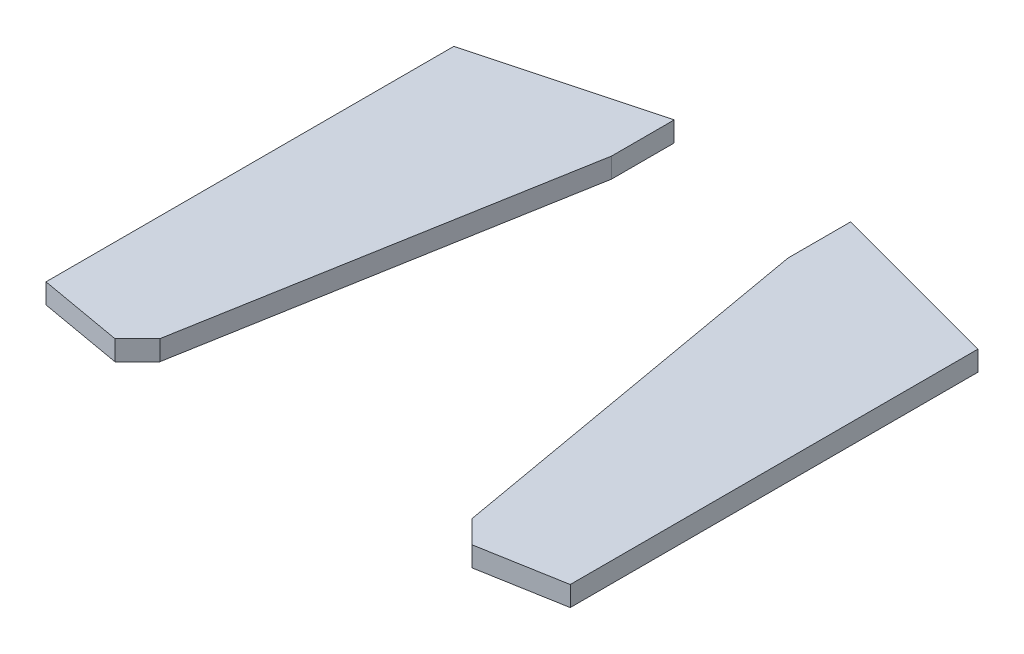
from build123d import *

# Parameters (mm, degrees)
BOSS_EXTRUDE1_DEPTH   = 75
BOSS_EXTRUDE1_2_DEPTH = 75


with BuildPart() as part:
    # Sketch2 → Boss-Extrude1 (new body)
    with BuildSketch(Plane(origin=(0, 0, 0), x_dir=(1, 0, 0), z_dir=(0, 1, 0))):
        Polygon((584.865866398, -719.738268583), (668.957787666, -803.830189852), (982.928076995, -748.468756703), (982.928076995, 780.737776155), (330.90540656, 955.446724145), (330.90540656, 720.543070197), align=None)
    extrude(amount=BOSS_EXTRUDE1_DEPTH)


with BuildPart() as body_2:
    # Sketch2 → Boss-Extrude1 2 (new body)
    with BuildSketch(Plane(origin=(0, 0, 0), x_dir=(1, 0, 0), z_dir=(0, 1, 0))):
        Polygon((-331.173673764, 720.543070197), (-331.173673764, 955.446724145), (-983.196344199, 780.737776155), (-983.196344199, -748.468756703), (-669.226054871, -803.830189852), (-585.134133602, -719.738268583), align=None)
    extrude(amount=BOSS_EXTRUDE1_2_DEPTH)


solid = Compound([part.part, body_2.part])
